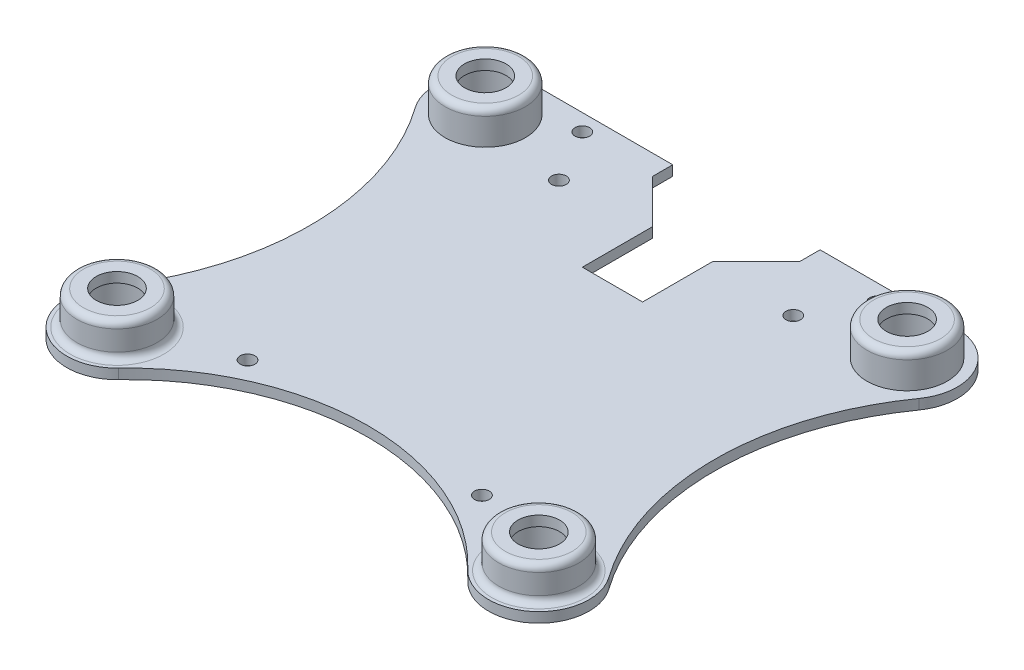
from build123d import *

# Parameters (mm, degrees)
BOSS_EXTRUDE1_DEPTH     = 1.5
CUT_EXTRUDE1_DEPTH      = 2.5
SKETCH6_R               = 6
BOSS_EXTRUDE3_DEPTH     = 5
SKETCH3_R               = 3.1
CUT_EXTRUDE2_DEPTH      = 6
CUT_EXTRUDE2_DEPTH_BACK = 2.5
SKETCH4_R               = 1.1
CUT_EXTRUDE3_DEPTH      = 2.5
SKETCH7_R               = 4.5
CUT_EXTRUDE5_DEPTH      = 5
FILLET1_R               = 1


with BuildPart() as part:
    # Sketch1 → Boss-Extrude1 (new body)
    with BuildSketch(Plane(origin=(0, 0, 0), x_dir=(1, 0, 0), z_dir=(0, 1, 0))):
        with BuildLine():
            Line((-31.5, 37.5), (31.5, 37.5))
            ThreePointArc((31.5, 37.5), (38.163924875, 33.441236008), (37.615236862, 25.657894737))
            ThreePointArc((37.615236862, 25.657894737), (30.229833462, 2.5), (37.615236862, -20.657894737))
            ThreePointArc((37.615236862, -20.657894737), (36.269544155, -30.788043586), (26.068965517, -30.172413793))
            ThreePointArc((26.068965517, -30.172413793), (0, -19), (-26.068965517, -30.172413793))
            ThreePointArc((-26.068965517, -30.172413793), (-36.269544155, -30.788043586), (-37.615236862, -20.657894737))
            ThreePointArc((-37.615236862, -20.657894737), (-30.229833462, 2.5), (-37.615236862, 25.657894737))
            ThreePointArc((-37.615236862, 25.657894737), (-38.163924875, 33.441236008), (-31.5, 37.5))
        make_face()
    extrude(amount=BOSS_EXTRUDE1_DEPTH)

    # Sketch2 → Cut-Extrude1 (cut, through all)
    with BuildSketch(Plane(origin=(0, 1.5, 0), x_dir=(1, 0, 0), z_dir=(0, 1, 0))):
        Polygon((-11, 37.5), (11, 37.5), (11, 34.5), (4.5, 28), (4.5, 17.5), (-4.5, 17.5), (-4.5, 28), (-11, 34.5), align=None)
    extrude(amount=-CUT_EXTRUDE1_DEPTH, mode=Mode.SUBTRACT)

    # Sketch6 → Boss-Extrude3 (add)
    with BuildSketch(Plane(origin=(0, 1.5, 0), x_dir=(1, 0, 0), z_dir=(0, 1, 0))):
        with Locations((-31.5, 30)):
            Circle(SKETCH6_R)
        with Locations((31.5, 30)):
            Circle(SKETCH6_R)
        with Locations((-31.5, -25)):
            Circle(SKETCH6_R)
        with Locations((31.5, -25)):
            Circle(SKETCH6_R)
    extrude(amount=BOSS_EXTRUDE3_DEPTH)

    # Sketch3 → Cut-Extrude2 (cut, two sides)
    with BuildSketch(Plane(origin=(0, 1.5, 0), x_dir=(1, 0, 0), z_dir=(0, 1, 0))) as cut_extrude2_sk:
        with Locations((-31.5, 30)):
            Circle(SKETCH3_R)
        with Locations((31.5, 30)):
            Circle(SKETCH3_R)
        with Locations((31.5, -25)):
            Circle(SKETCH3_R)
        with Locations((-31.5, -25)):
            Circle(SKETCH3_R)
    extrude(amount=CUT_EXTRUDE2_DEPTH, mode=Mode.SUBTRACT)
    extrude(cut_extrude2_sk.sketch, amount=-CUT_EXTRUDE2_DEPTH_BACK, mode=Mode.SUBTRACT)

    # Sketch4 → Cut-Extrude3 (cut, through all)
    with BuildSketch(Plane(origin=(0, 1.5, 0), x_dir=(1, 0, 0), z_dir=(0, 1, 0))):
        with Locations((-17.5, 27)):
            Circle(SKETCH4_R)
        with Locations((17.5, 27)):
            Circle(SKETCH4_R)
        with Locations((-22, 35)):
            Circle(SKETCH4_R)
        with Locations((22, 35)):
            Circle(SKETCH4_R)
        with Locations((-17.5, -19.5)):
            Circle(SKETCH4_R)
        with Locations((17.5, -19.5)):
            Circle(SKETCH4_R)
    extrude(amount=-CUT_EXTRUDE3_DEPTH, mode=Mode.SUBTRACT)

    # Sketch7 → Cut-Extrude5 (cut)
    with BuildSketch(Plane.XZ):
        with Locations((-31.5, -30)):
            Circle(SKETCH7_R)
        with Locations((31.5, -30)):
            Circle(SKETCH7_R)
        with Locations((-31.5, 25)):
            Circle(SKETCH7_R)
        with Locations((31.5, 25)):
            Circle(SKETCH7_R)
    extrude(amount=-CUT_EXTRUDE5_DEPTH, mode=Mode.SUBTRACT)

    # Fillet1
    fillet1_edges = [part.edges().sort_by_distance(p)[0] for p in [
        (-37.5, 6.5, -30),
        (25.5, 6.5, -30),
        (-37.5, 1.5, 25),
        (-37.5, 6.5, 25),
        (25.5, 1.5, 25),
        (25.5, 6.5, 25),
    ]]
    fillet(fillet1_edges, radius=FILLET1_R)


solid = part.part
